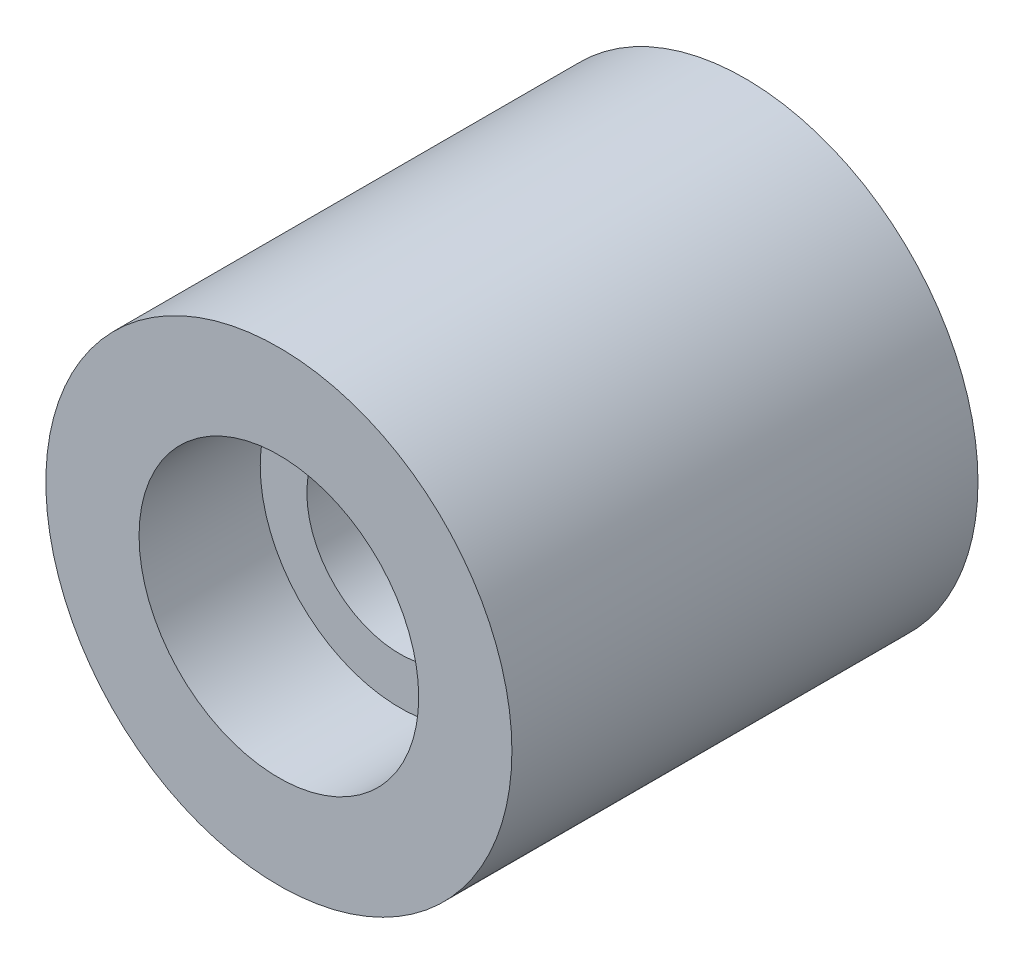
from build123d import *


with BuildPart() as part:
    # Croquis2 → Revolución1 (revolve)
    with BuildSketch(Plane(origin=(0, 0, 0), x_dir=(1, 0, 0), z_dir=(0, 1, 0))):
        Polygon((-1.5, 0), (-2.5, 0), (-2.5, 5), (-1, 5), (-1, 4.5), (-2, 4.5), (-2, 1.8), (-1, 1.8), (-1, 1.3), (-1.5, 1.3), align=None)
    revolve(axis=Axis((0, 0, 0), (0, 0, -1)))


solid = part.part
